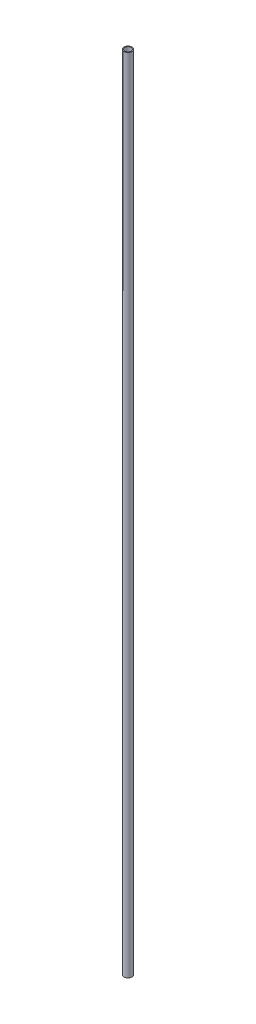
from build123d import *

# Parameters (mm, degrees)
SKETCH1_R           = 5
SKETCH1_R_2         = 4
BOSS_EXTRUDE1_DEPTH = 1000


with BuildPart() as part:
    # Sketch1 → Boss-Extrude1 (new body)
    with BuildSketch(Plane(origin=(0, 0, 0), x_dir=(1, 0, 0), z_dir=(0, 1, 0))):
        Circle(SKETCH1_R)
        Circle(SKETCH1_R_2, mode=Mode.SUBTRACT)
    extrude(amount=BOSS_EXTRUDE1_DEPTH)


solid = part.part
